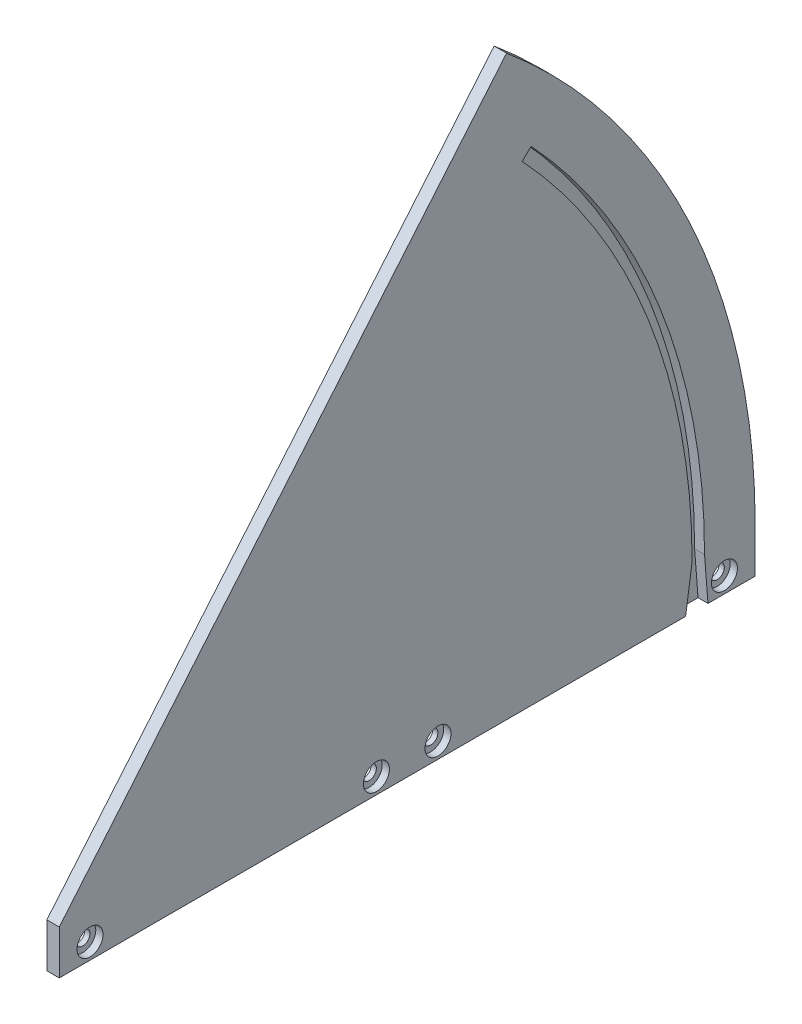
from build123d import *

# Parameters (mm, degrees)
BOSS_EXTRUDE1_DEPTH = 3.175
SKETCH2_W           = 3.175
SKETCH2_H           = 178.054
BOSS_EXTRUDE2_DEPTH = 11.303
SKETCH3_R           = 1.8288
CUT_EXTRUDE1_DEPTH  = 4.175
CUT_EXTRUDE2_DEPTH  = 2.54
SKETCH8_R           = 3.3274
CUT_EXTRUDE3_DEPTH  = 1.8542


with BuildPart() as part:
    # Sketch1 → Boss-Extrude1 (new body)
    with BuildSketch(Plane(origin=(0, 0, 0), x_dir=(0, 0, -1), z_dir=(1, 0, 0))):
        with BuildLine():
            Line((0, 0), (178.054, 0))
            ThreePointArc((178.054, 0), (161.371726713, 75.248871976), (114.450905055, 136.397277275))
            Line((114.450905055, 136.397277275), (0, 0))
        make_face()
    extrude(amount=BOSS_EXTRUDE1_DEPTH)

    # Sketch2 → Boss-Extrude2 (add)
    with BuildSketch(Plane.XZ):
        with Locations((1.5875, -89.027)):
            Rectangle(SKETCH2_W, SKETCH2_H)
    extrude(amount=BOSS_EXTRUDE2_DEPTH)

    # Sketch3 → Cut-Extrude1 (cut, through all)
    with BuildSketch(Plane(origin=(3.175, 0, 0), x_dir=(0, 0, -1), z_dir=(1, 0, 0))):
        with Locations((7.874, -7.239)):
            Circle(SKETCH3_R)
        with Locations((81.153, -7.239)):
            Circle(SKETCH3_R)
        with Locations((96.901, -7.239)):
            Circle(SKETCH3_R)
        with Locations((170.18, -7.239)):
            Circle(SKETCH3_R)
    extrude(amount=-CUT_EXTRUDE1_DEPTH, mode=Mode.SUBTRACT)

    # Sketch6 → Cut-Extrude2 (cut)
    with BuildSketch(Plane(origin=(3.175, 0, 0), x_dir=(0, 0, -1), z_dir=(1, 0, 0))):
        with BuildLine():
            Line((165.1, 0), (165.982635189, -11.303))
            Line((165.982635189, -11.303), (160.260021408, -11.303))
            Line((160.260021408, -11.303), (161.925, 0))
            ThreePointArc((161.925, 0), (150.657864695, 59.345711137), (118.424448135, 110.432584453))
            Line((118.424448135, 110.432584453), (120.746496137, 112.597929246))
            ThreePointArc((120.746496137, 112.597929246), (153.611940474, 60.509352532), (165.1, 0))
        make_face()
    extrude(amount=-CUT_EXTRUDE2_DEPTH, mode=Mode.SUBTRACT)

    # Sketch8 → Cut-Extrude3 (cut)
    with BuildSketch(Plane(origin=(3.175, 0, 0), x_dir=(0, 0, -1), z_dir=(1, 0, 0))):
        with Locations((7.874, -7.239)):
            Circle(SKETCH8_R)
        with Locations((81.153, -7.239)):
            Circle(SKETCH8_R)
        with Locations((96.901, -7.239)):
            Circle(SKETCH8_R)
        with Locations((170.18, -7.239)):
            Circle(SKETCH8_R)
    extrude(amount=-CUT_EXTRUDE3_DEPTH, mode=Mode.SUBTRACT)


solid = part.part
